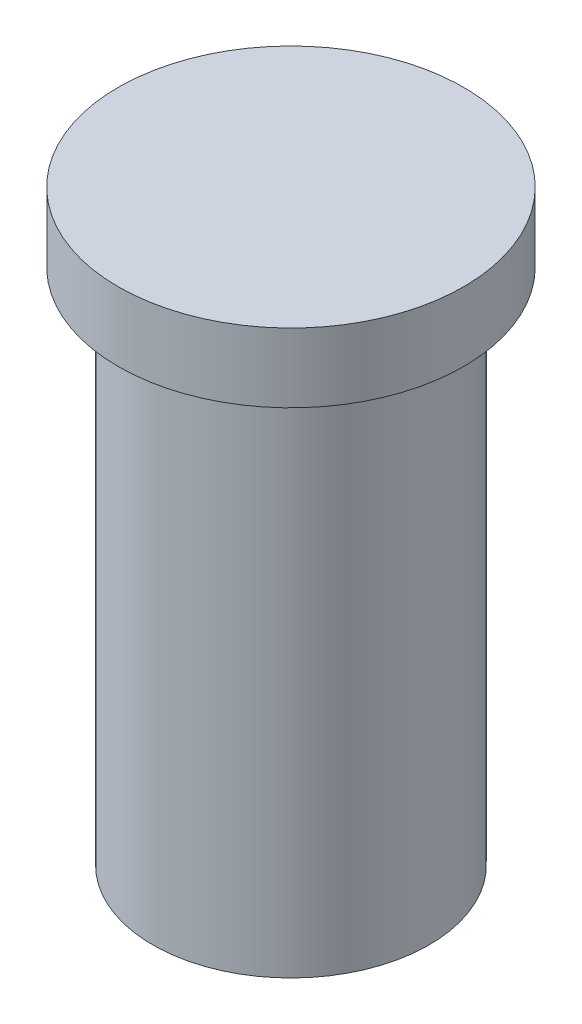
from build123d import *

# Parameters (mm, degrees)
SKETCH1_R           = 5
BOSS_EXTRUDE1_DEPTH = 2
SKETCH6_R           = 4
BOSS_EXTRUDE4_DEPTH = 15


with BuildPart() as part:
    # Sketch1 → Boss-Extrude1 (new body)
    with BuildSketch(Plane(origin=(0, 0, 0), x_dir=(1, 0, 0), z_dir=(0, 1, 0))):
        Circle(SKETCH1_R)
    extrude(amount=BOSS_EXTRUDE1_DEPTH)

    # Sketch6 → Boss-Extrude4 (add)
    with BuildSketch(Plane(origin=(0, 0, 0), x_dir=(-1, 0, 0), z_dir=(0, -1, 0))):
        Circle(SKETCH6_R)
    extrude(amount=BOSS_EXTRUDE4_DEPTH)


solid = part.part
